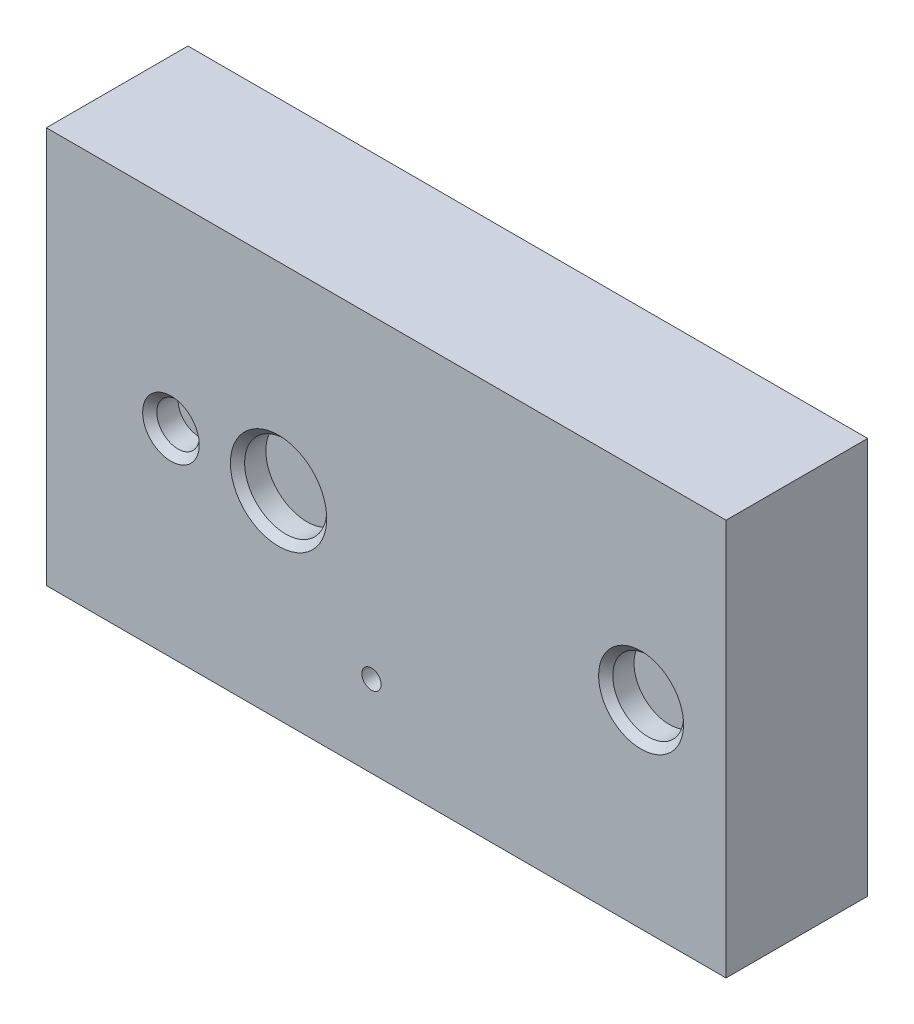
from build123d import *

# Parameters (mm, degrees)
SKETCH1_W           = 4.8
SKETCH1_H           = 2.8
BOSS_EXTRUDE1_DEPTH = 1
SKETCH2_R           = 0.25
SKETCH2_R_2         = 0.068106799
SKETCH2_R_3         = 0.29
SKETCH2_R_4         = 0.15
CUT_EXTRUDE1_DEPTH  = 0.2
CHAMFER1_SIZE       = 0.05
SKETCH3_W           = 0.55
SKETCH3_H           = 0.6
CUT_EXTRUDE2_DEPTH  = 0.001


with BuildPart() as part:
    # Sketch1 → Boss-Extrude1 (new body)
    with BuildSketch(Plane.XY):
        Rectangle(SKETCH1_W, SKETCH1_H)
    extrude(amount=BOSS_EXTRUDE1_DEPTH)

    # Sketch2 → Cut-Extrude1 (cut)
    with BuildSketch(Plane.XY.offset(1)):
        with Locations((1.8, 0)):
            Circle(SKETCH2_R)
        with Locations((-0.104016801, -0.823903451)):
            Circle(SKETCH2_R_2)
        with Locations((-0.76, 0)):
            Circle(SKETCH2_R_3)
        with Locations((-1.52, 0)):
            Circle(SKETCH2_R_4)
    extrude(amount=-CUT_EXTRUDE1_DEPTH, mode=Mode.SUBTRACT)

    # Chamfer1
    chamfer1_edges = [part.edges().sort_by_distance(p)[0] for p in [
        (1.55, 0, 1),
        (-1.05, 0, 1),
        (-1.67, 0, 1),
    ]]
    chamfer(chamfer1_edges, length=CHAMFER1_SIZE)

    # Sketch3 → Cut-Extrude2 (cut)
    with BuildSketch(Plane(origin=(0, 0, 0), x_dir=(-1, 0, 0), z_dir=(0, 0, -1))):
        with Locations((1.875, -1)):
            Rectangle(SKETCH3_W, SKETCH3_H)
        with Locations((1.125, -1)):
            Rectangle(SKETCH3_W, SKETCH3_H)
        with Locations((0.375, -1)):
            Rectangle(SKETCH3_W, SKETCH3_H)
        with Locations((-0.375, -1)):
            Rectangle(SKETCH3_W, SKETCH3_H)
        with Locations((-1.125, -1)):
            Rectangle(SKETCH3_W, SKETCH3_H)
        with Locations((-1.875, -1)):
            Rectangle(SKETCH3_W, SKETCH3_H)
        with Locations((1.125, 1)):
            Rectangle(SKETCH3_W, SKETCH3_H)
        with Locations((0.375, 1)):
            Rectangle(SKETCH3_W, SKETCH3_H)
        with Locations((-0.375, 1)):
            Rectangle(SKETCH3_W, SKETCH3_H)
        with Locations((-1.125, 1)):
            Rectangle(SKETCH3_W, SKETCH3_H)
        with Locations((-1.875, 1)):
            Rectangle(SKETCH3_W, SKETCH3_H)
        with Locations((1.875, 1)):
            Rectangle(SKETCH3_W, SKETCH3_H)
    extrude(amount=-CUT_EXTRUDE2_DEPTH, mode=Mode.SUBTRACT)


solid = part.part
